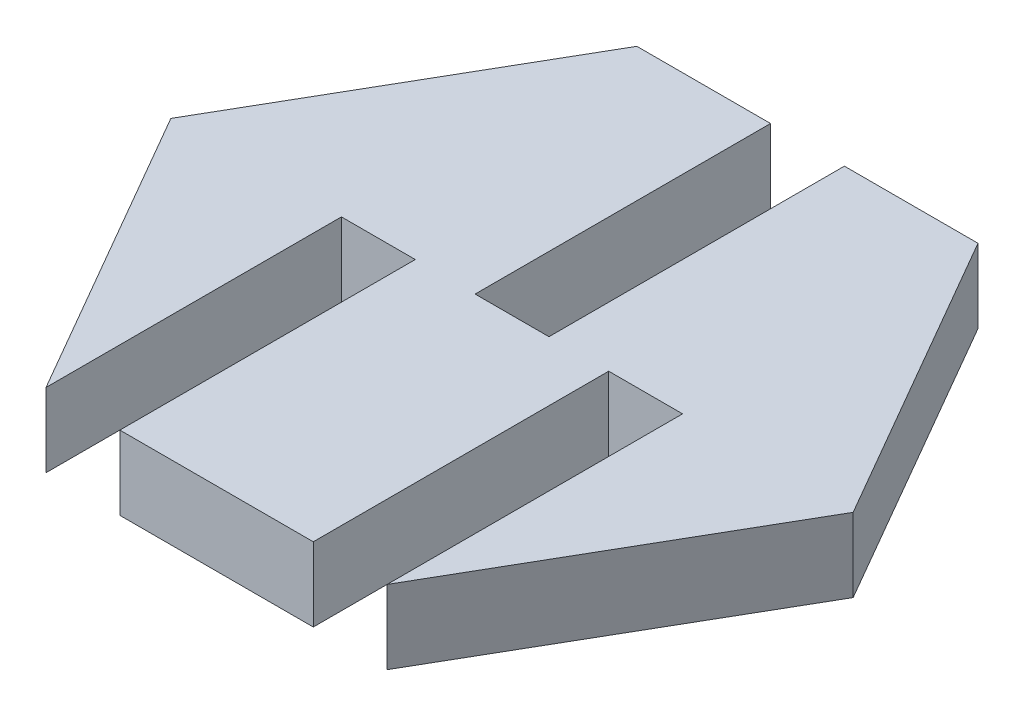
from build123d import *

# Parameters (mm, degrees)
BOSS_EXTRUDE1_DEPTH = 2.5
SKETCH5_W           = 2.5
SKETCH5_H           = 2.5
CUT_EXTRUDE3_DEPTH  = 10
SKETCH6_W           = 2.5
SKETCH6_H           = 2.5
CUT_EXTRUDE4_DEPTH  = 10
SKETCH7_W           = 2.5
SKETCH7_H           = 2.5
CUT_EXTRUDE5_DEPTH  = 10


with BuildPart() as part:
    # Sketch1 → Boss-Extrude1 (new body)
    with BuildSketch(Plane(origin=(0, 0, 0), x_dir=(1, 0, 0), z_dir=(0, 1, 0))):
        Polygon((11.547005384, 0), (5.773502692, 10), (-5.773502692, 10), (-11.547005384, 0), (-5.773502692, -10), (5.773502692, -10), align=None)
    extrude(amount=BOSS_EXTRUDE1_DEPTH)

    # Sketch5 → Cut-Extrude3 (cut)
    with BuildSketch(Plane.XY.offset(10)):
        with Locations((-4.523502692, 1.25)):
            Rectangle(SKETCH5_W, SKETCH5_H)
    extrude(amount=-CUT_EXTRUDE3_DEPTH, mode=Mode.SUBTRACT)

    # Sketch6 → Cut-Extrude4 (cut)
    with BuildSketch(Plane.XY.offset(10)):
        with Locations((4.523502692, 1.25)):
            Rectangle(SKETCH6_W, SKETCH6_H)
    extrude(amount=-CUT_EXTRUDE4_DEPTH, mode=Mode.SUBTRACT)

    # Sketch7 → Cut-Extrude5 (cut)
    with BuildSketch(Plane(origin=(0, 0, -10), x_dir=(-1, 0, 0), z_dir=(0, 0, -1))):
        with Locations((-0.001497308, 1.25)):
            Rectangle(SKETCH7_W, SKETCH7_H)
    extrude(amount=-CUT_EXTRUDE5_DEPTH, mode=Mode.SUBTRACT)


solid = part.part
